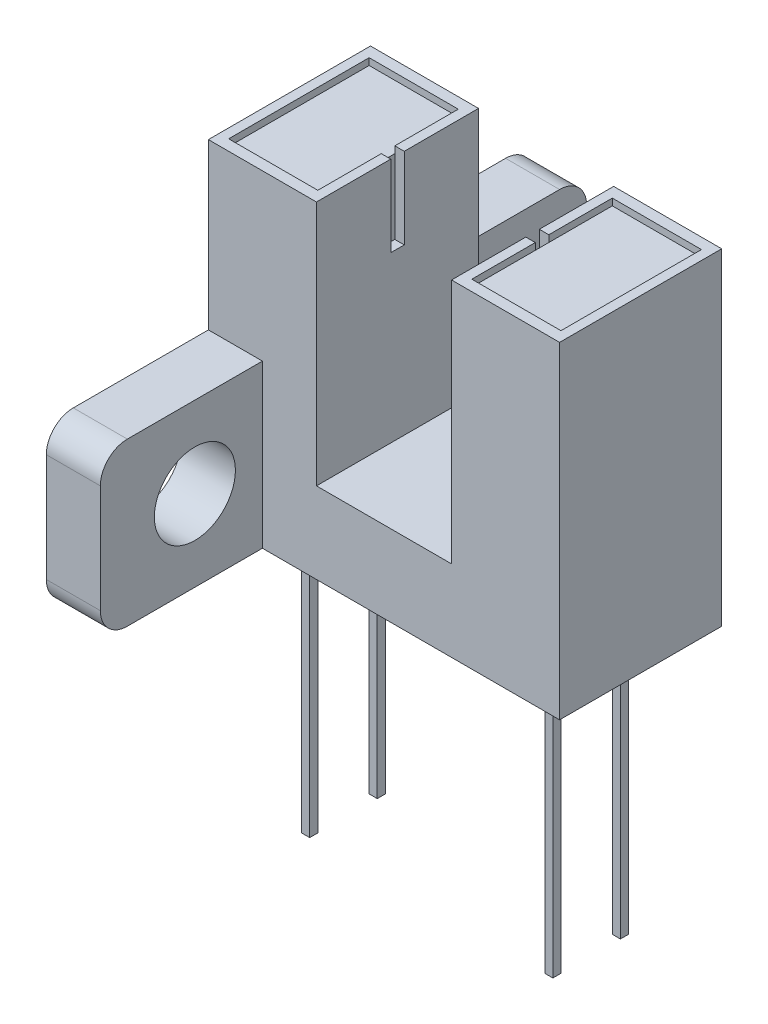
from build123d import *

# Parameters (mm, degrees)
BOSS_EXTRUDE1_DEPTH  = 3
SKETCH3_W            = 18
SKETCH3_H            = 6
BOSS_EXTRUDE2_DEPTH  = 2
SKETCH4_R            = 1.5
CUT_EXTRUDE1_DEPTH   = 14
FILLET1_R            = 1
SKETCH5_W            = 3.3
SKETCH5_H            = 5.2
CUT_EXTRUDE2_DEPTH   = 0.25
SKETCH6_W            = 0.5
SKETCH6_H            = 3
CUT_EXTRUDE3_DEPTH   = 0.35
SKETCH7_W            = 12
SKETCH7_H            = 5
CUT_EXTRUDE4_DEPTH   = 2
SKETCH8_W            = 0.3
SKETCH8_H            = 0.3
BOSS_EXTRUDE3_DEPTH  = 12
LPATTERN1_COUNT      = 2
LPATTERN1_PITCH      = 9
LPATTERN1_COUNT_DIR2 = 2
LPATTERN1_PITCH_DIR2 = 2.5


with BuildPart() as part:
    # Sketch1 → Boss-Extrude1 (new body, symmetric)
    with BuildSketch(Plane.XY):
        Polygon((-9, 12.1), (-13, 12.1), (-13, 0), (0, 0), (0, 12.1), (-4, 12.1), (-4, 3), (-9, 3), align=None)
    extrude(amount=BOSS_EXTRUDE1_DEPTH, both=True)

    # Sketch3 → Boss-Extrude2 (add)
    with BuildSketch(Plane.ZY.offset(13)):
        with Locations((0, 3)):
            Rectangle(SKETCH3_W, SKETCH3_H)
    extrude(amount=-BOSS_EXTRUDE2_DEPTH)

    # Sketch4 → Cut-Extrude1 (cut, through all)
    with BuildSketch(Plane.ZY.offset(13)):
        with Locations((-5.5, 3)):
            Circle(SKETCH4_R)
        with Locations((5.5, 3)):
            Circle(SKETCH4_R)
    extrude(amount=-CUT_EXTRUDE1_DEPTH, mode=Mode.SUBTRACT)

    # Fillet1
    fillet1_edges = [part.edges().sort_by_distance(p)[0] for p in [
        (-12, 6, -9),
        (-12, 0, -9),
        (-12, 6, 9),
        (-12, 0, 9),
    ]]
    fillet(fillet1_edges, radius=FILLET1_R)

    # Sketch5 → Cut-Extrude2 (cut)
    with BuildSketch(Plane(origin=(0, 12.1, 0), x_dir=(1, 0, 0), z_dir=(0, 1, 0))):
        with Locations((-11, 0)):
            Rectangle(SKETCH5_W, SKETCH5_H)
    cut_extrude2 = extrude(amount=-CUT_EXTRUDE2_DEPTH, mode=Mode.SUBTRACT)

    # Sketch6 → Cut-Extrude3 (cut)
    with BuildSketch(Plane(origin=(-9, 0, 0), x_dir=(0, 0, -1), z_dir=(1, 0, 0))):
        with Locations((0, 10.6)):
            Rectangle(SKETCH6_W, SKETCH6_H)
    cut_extrude3 = extrude(amount=-CUT_EXTRUDE3_DEPTH, mode=Mode.SUBTRACT)

    # Mirror1: Cut-Extrude2, Cut-Extrude3 across plane
    add(cut_extrude2.mirror(Plane(origin=(-6.5, 0, 0), x_dir=(0, 0, 1), z_dir=(1, 0, 0))), mode=Mode.SUBTRACT)
    add(cut_extrude3.mirror(Plane(origin=(-6.5, 0, 0), x_dir=(0, 0, 1), z_dir=(1, 0, 0))), mode=Mode.SUBTRACT)

    # Sketch7 → Cut-Extrude4 (cut)
    with BuildSketch(Plane.XZ):
        with Locations((-6.5, 0)):
            Rectangle(SKETCH7_W, SKETCH7_H)
    extrude(amount=-CUT_EXTRUDE4_DEPTH, mode=Mode.SUBTRACT)

    # Sketch8 → Boss-Extrude3 (add)
    with BuildSketch(Plane.XZ.offset(-2)):
        with Locations((-11, 1.25)):
            Rectangle(SKETCH8_W, SKETCH8_H)
    boss_extrude3 = extrude(amount=BOSS_EXTRUDE3_DEPTH)

    # LPattern1: Boss-Extrude3 2 × 2
    with Locations(*[(i * LPATTERN1_PITCH, 0, -j * LPATTERN1_PITCH_DIR2) for i in range(LPATTERN1_COUNT) for j in range(LPATTERN1_COUNT_DIR2) if (i, j) != (0, 0)]):
        add(boss_extrude3)


solid = part.part
